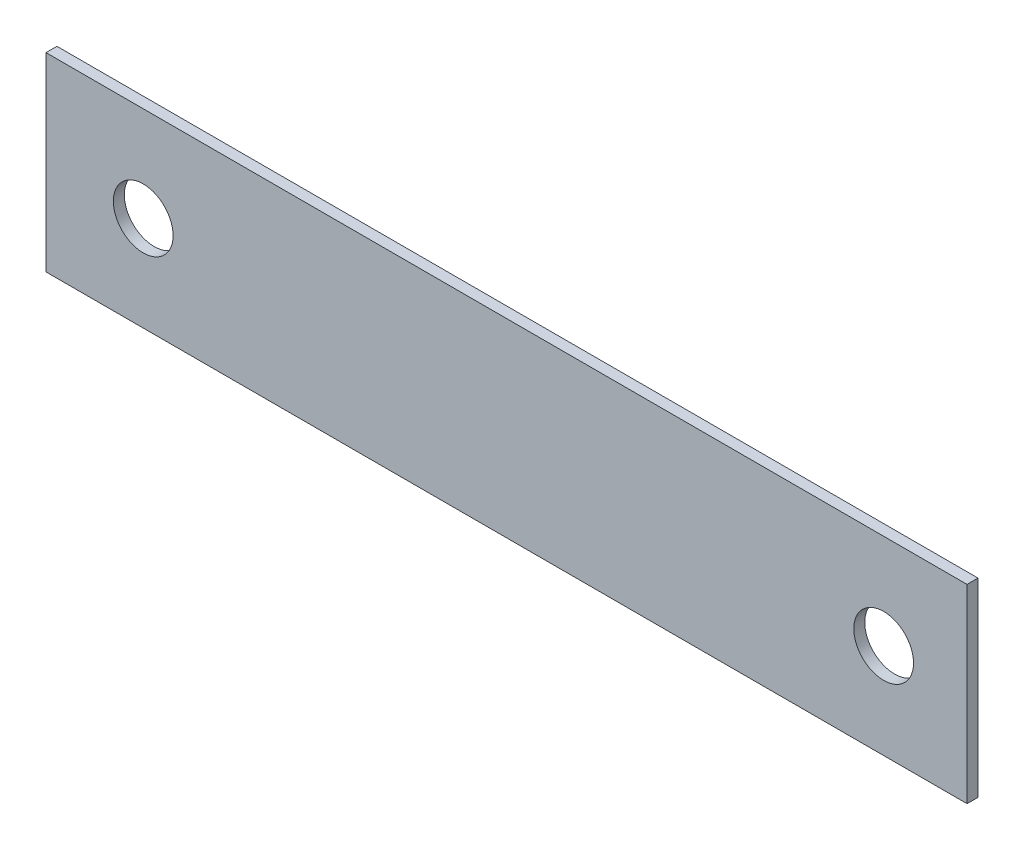
from build123d import *

# Parameters (mm, degrees)
SKETCH1_W           = 37
SKETCH1_H           = 7.63
SKETCH1_R           = 1.2
BOSS_EXTRUDE1_DEPTH = 0.44
SKETCH3_R           = 1.05
BOSS_EXTRUDE2_DEPTH = 4.85


with BuildPart() as part:
    # Sketch1 → Boss-Extrude1 (new body)
    with BuildSketch(Plane.XY):
        Rectangle(SKETCH1_W, SKETCH1_H)
        with Locations((-14.59410802, 0)):
            Circle(SKETCH1_R, mode=Mode.SUBTRACT)
        with Locations((15.15, 0)):
            Circle(SKETCH1_R, mode=Mode.SUBTRACT)
    extrude(amount=BOSS_EXTRUDE1_DEPTH)

    # Sketch3 → Boss-Extrude2 (add)
    with BuildSketch(Plane(origin=(-5.295, 0, 0), x_dir=(0, 0, -1), z_dir=(1, 0, 0))):
        with BuildLine():
            Line((2.227470567, 0.890666365), (0, 2.71))
            Line((0, 2.71), (0, -2.71))
            Line((0, -2.71), (2.227470567, -0.890666365))
            ThreePointArc((2.227470567, -0.890666365), (2.65, 0), (2.227470567, 0.890666365))
        make_face()
        with Locations((1.5, 0)):
            Circle(SKETCH3_R, mode=Mode.SUBTRACT)
    boss_extrude2 = extrude(amount=-BOSS_EXTRUDE2_DEPTH)

    # Mirror1: Boss-Extrude2 across plane
    add(boss_extrude2.mirror(Plane(origin=(0, 0, 0), x_dir=(0, 0, 1), z_dir=(1, 0, 0))))


solid = part.part
